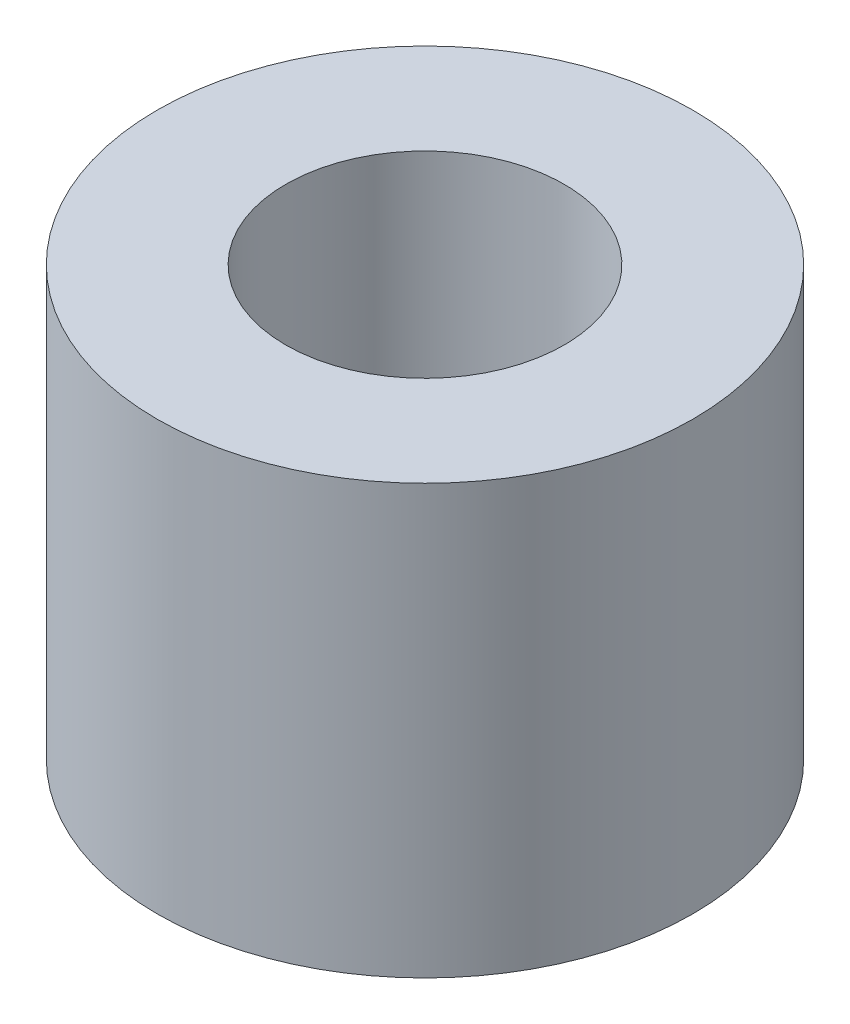
from build123d import *

# Parameters (mm, degrees)
SKETCH2_R           = 6.35
SKETCH2_R_2         = 3.302
BOSS_EXTRUDE1_DEPTH = 10.16


with BuildPart() as part:
    # Sketch2 → Boss-Extrude1 (new body)
    with BuildSketch(Plane(origin=(0, 0, 0), x_dir=(1, 0, 0), z_dir=(0, 1, 0))):
        Circle(SKETCH2_R)
        Circle(SKETCH2_R_2, mode=Mode.SUBTRACT)
    extrude(amount=BOSS_EXTRUDE1_DEPTH)


solid = part.part
